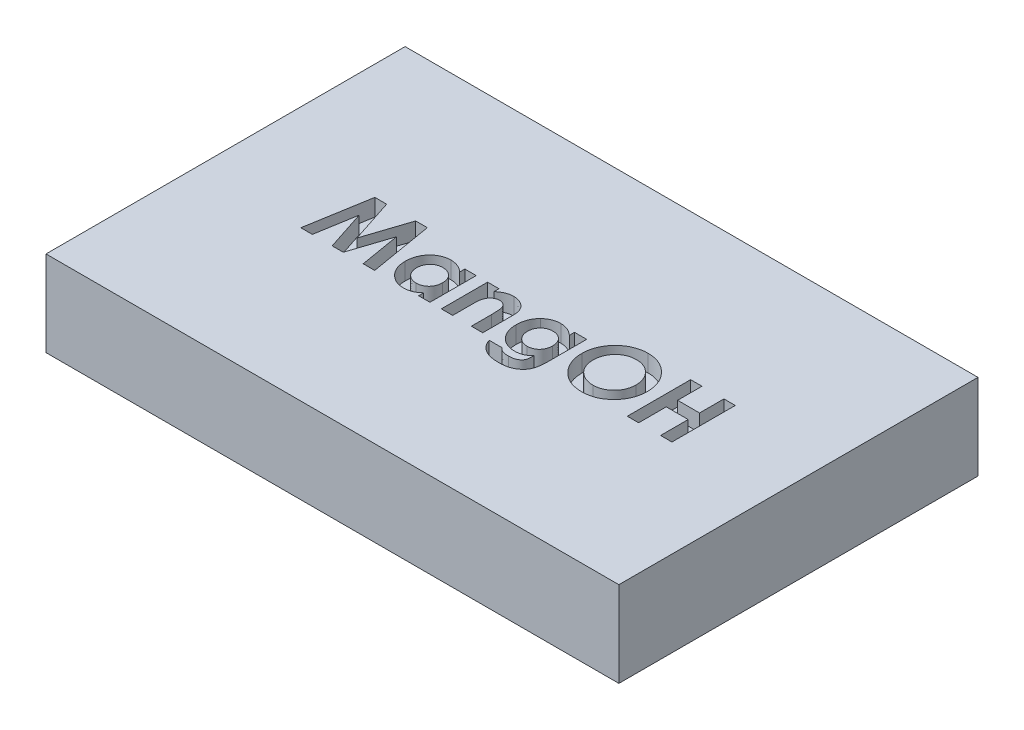
from build123d import *

# Parameters (mm, degrees)
SKETCH4_W           = 67
SKETCH4_H           = 42
BOSS_EXTRUDE1_DEPTH = 10
CUT_EXTRUDE1_DEPTH  = 2


with BuildPart() as part:
    # Sketch4 → Boss-Extrude1 (new body)
    with BuildSketch(Plane(origin=(0, 0, 0), x_dir=(1, 0, 0), z_dir=(0, 1, 0))):
        Rectangle(SKETCH4_W, SKETCH4_H)
    extrude(amount=BOSS_EXTRUDE1_DEPTH)

    # Sketch5 → Cut-Extrude1 (cut)
    with BuildSketch(Plane(origin=(0, 10, 0), x_dir=(1, 0, 0), z_dir=(0, 1, 0))):
        Polygon((-20.000405703, 3.960288306), (-18.62024745, 3.960288306), (-16.9299246, -1.207142917), (-15.227729421, 3.960288306), (-13.860927538, 3.960288306), (-12.608396822, -3.448045027), (-13.954422129, -3.448045027), (-14.745416053, 1.231136664), (-16.285850749, -3.448045027), (-17.582902698, -3.448045027), (-19.114433147, 1.231136664), (-19.90394303, -3.448045027), (-21.251452378, -3.448045027), align=None)
        with BuildLine():
            Line((-7.479550668, 1.965737024), (-6.149849814, 1.965737024))
            Line((-6.149849814, 1.965737024), (-6.149849814, -3.448045027))
            Line((-6.149849814, -3.448045027), (-7.479550668, -3.448045027))
            Line((-7.479550668, -3.448045027), (-7.479550668, -2.857396656))
            add(Edge.make_bspline(
                [(-7.479550668, -2.857396656), (-7.545436856, -2.914889738), (-7.673308935, -3.026472456), (-7.874793953, -3.17125387), (-8.076867735, -3.290679824), (-8.280501249, -3.385796084), (-8.488824257, -3.456029652), (-8.703336601, -3.506880396), (-8.927127489, -3.536868324), (-9.079257451, -3.540950509), (-9.156517148, -3.54302366)],
                knots=[0, 0, 0, 0, 0.000262222, 0.000508921, 0.00074308, 0.000965513, 0.001181863, 0.001401441, 0.001626017, 0.00185776, 0.00185776, 0.00185776, 0.00185776], degree=3))
            add(Edge.make_bspline(
                [(-9.156517148, -3.54302366), (-9.243244593, -3.541072563), (-9.41462294, -3.537217087), (-9.666101638, -3.496631973), (-9.908929322, -3.43450741), (-10.142908884, -3.346593389), (-10.367614619, -3.232674053), (-10.584766207, -3.095721717), (-10.790641008, -2.930928533), (-10.986952861, -2.745424685), (-11.166694815, -2.541369131), (-11.323826928, -2.321594136), (-11.456277622, -2.089216722), (-11.564787387, -1.845007328), (-11.650144331, -1.589145189), (-11.710991617, -1.320818789), (-11.746891587, -1.039932295), (-11.751334991, -0.848603415), (-11.75358913, -0.751542289)],
                knots=[0, 0, 0, 0, 0.000259978, 0.000513732, 0.000762095, 0.001010999, 0.001261872, 0.001516717, 0.001779777, 0.002051665, 0.002326132, 0.002594223, 0.00286076, 0.003127165, 0.003394663, 0.003668632, 0.003951368, 0.004242483, 0.004242483, 0.004242483, 0.004242483], degree=3))
            add(Edge.make_bspline(
                [(-11.75358913, -0.751542289), (-11.751223403, -0.651035366), (-11.746582766, -0.453879837), (-11.712636781, -0.164563472), (-11.652912355, 0.110416059), (-11.571473808, 0.371439643), (-11.466717259, 0.618552374), (-11.339130781, 0.852159102), (-11.186978681, 1.071649218), (-11.011650357, 1.273286843), (-10.822338831, 1.458097467), (-10.619808965, 1.61898977), (-10.407227883, 1.755675268), (-10.184369682, 1.867263678), (-9.951266186, 1.953493554), (-9.708837684, 2.016534634), (-9.456007965, 2.054361497), (-9.283778312, 2.058580013), (-9.196586259, 2.060715657)],
                knots=[0, 0, 0, 0, 0.000301494, 0.000591414, 0.000872306, 0.001144538, 0.001410529, 0.001676189, 0.001941716, 0.002210049, 0.002476623, 0.002734351, 0.002984644, 0.003233526, 0.003480519, 0.003728882, 0.003983883, 0.004245344, 0.004245344, 0.004245344, 0.004245344], degree=3))
            add(Edge.make_bspline(
                [(-9.196586259, 2.060715657), (-9.115818166, 2.059037683), (-8.956007223, 2.055717577), (-8.721108163, 2.019667582), (-8.493289954, 1.965144524), (-8.273795356, 1.887458982), (-8.060824001, 1.78936518), (-7.858039131, 1.666446334), (-7.661004644, 1.523868669), (-7.540782628, 1.412512493), (-7.479550668, 1.355796119)],
                knots=[0, 0, 0, 0, 0.000242122, 0.000479071, 0.000711233, 0.000944033, 0.001176417, 0.001413367, 0.00165439, 0.001904573, 0.001904573, 0.001904573, 0.001904573], degree=3))
            Line((-7.479550668, 1.355796119), (-7.479550668, 1.965737024))
        make_face()
        with BuildLine():
            add(Edge.make_bspline(
                [(-8.917586526, 0.825993434), (-8.970571185, 0.824367682), (-9.074417658, 0.821181314), (-9.227138108, 0.802015087), (-9.373093043, 0.76824334), (-9.511241526, 0.718352837), (-9.643642475, 0.657578935), (-9.768285362, 0.581460623), (-9.886198902, 0.491490396), (-9.996689633, 0.389846431), (-10.097418215, 0.27812113), (-10.184252131, 0.156204619), (-10.258046931, 0.027381857), (-10.320458153, -0.108734483), (-10.365130428, -0.253755078), (-10.400510851, -0.405792018), (-10.418871, -0.566087366), (-10.422199116, -0.675323685), (-10.423888275, -0.730765714)],
                knots=[0, 0, 0, 0, 0.000158966, 0.000311562, 0.00046095, 0.000607397, 0.000751472, 0.000897308, 0.001044528, 0.001195769, 0.001347112, 0.001494959, 0.001643874, 0.001791996, 0.00194312, 0.002098293, 0.002259727, 0.002426105, 0.002426105, 0.002426105, 0.002426105], degree=3))
            add(Edge.make_bspline(
                [(-10.423888275, -0.730765714), (-10.422224919, -0.786710633), (-10.418947294, -0.896949449), (-10.400213985, -1.058596946), (-10.366106696, -1.212854788), (-10.316345446, -1.358475906), (-10.255575418, -1.49742521), (-10.181604628, -1.629061436), (-10.090744467, -1.75105709), (-9.989927586, -1.866299001), (-9.877170155, -1.969205554), (-9.758589413, -2.060577126), (-9.63256564, -2.137027661), (-9.500466105, -2.198815467), (-9.362735462, -2.249167336), (-9.217646985, -2.28251464), (-9.066622, -2.303832941), (-8.963664279, -2.306801653), (-8.911650361, -2.308301437)],
                knots=[0, 0, 0, 0, 0.000167861, 0.000330768, 0.000487388, 0.000640849, 0.000791682, 0.000941885, 0.001092674, 0.001247221, 0.00140056, 0.001549859, 0.001695696, 0.001841744, 0.001986793, 0.002134736, 0.002287528, 0.002443529, 0.002443529, 0.002443529, 0.002443529], degree=3))
            add(Edge.make_bspline(
                [(-8.911650361, -2.308301437), (-8.857678801, -2.306666571), (-8.751865202, -2.303461344), (-8.596653196, -2.284470029), (-8.448737562, -2.250574455), (-8.308733709, -2.200398318), (-8.174503211, -2.140060652), (-8.047257379, -2.06542975), (-7.92837702, -1.97566598), (-7.817260062, -1.873103151), (-7.715442789, -1.760465545), (-7.627408029, -1.636950293), (-7.550726532, -1.506507752), (-7.490420063, -1.366053784), (-7.442528269, -1.218045677), (-7.408167011, -1.061564863), (-7.38947648, -0.896442636), (-7.38622752, -0.783740282), (-7.384572036, -0.72631359)],
                knots=[0, 0, 0, 0, 0.000161931, 0.000317472, 0.000468305, 0.000616151, 0.000762922, 0.000909271, 0.001057675, 0.001208916, 0.001362355, 0.001512272, 0.001663215, 0.001815407, 0.001969811, 0.00212933, 0.002295185, 0.002467493, 0.002467493, 0.002467493, 0.002467493], degree=3))
            add(Edge.make_bspline(
                [(-7.384572036, -0.72631359), (-7.386206949, -0.669874611), (-7.38940041, -0.559632889), (-7.408247619, -0.397958336), (-7.442852822, -0.24455009), (-7.489758923, -0.099126168), (-7.551138263, 0.037980921), (-7.62787778, 0.165250986), (-7.714946849, 0.287093458), (-7.817891386, 0.396688098), (-7.928406399, 0.498508293), (-8.049035086, 0.585557541), (-8.175976988, 0.660578999), (-8.310012038, 0.722174509), (-8.452381342, 0.767326354), (-8.600549754, 0.802285774), (-8.756829008, 0.821169811), (-8.863126227, 0.824359321), (-8.917586526, 0.825993434)],
                knots=[0, 0, 0, 0, 0.000169343, 0.000330777, 0.000487398, 0.000640391, 0.000788512, 0.000936894, 0.00108561, 0.001236851, 0.001387091, 0.001535807, 0.001682156, 0.001828926, 0.001977226, 0.002129505, 0.002285047, 0.00244846, 0.00244846, 0.00244846, 0.00244846], degree=3))
        make_face(mode=Mode.SUBTRACT)
        with BuildLine():
            Line((-4.820148959, 1.965737024), (-3.490448104, 1.965737024))
            Line((-3.490448104, 1.965737024), (-3.490448104, 1.392897147))
            add(Edge.make_bspline(
                [(-3.490448104, 1.392897147), (-3.41458933, 1.451901664), (-3.269608465, 1.564670767), (-3.049212518, 1.708451947), (-2.841186032, 1.82613107), (-2.640891873, 1.915643833), (-2.4445615, 1.980044417), (-2.249015204, 2.026312394), (-2.051340903, 2.055939052), (-1.91845579, 2.059124309), (-1.852066694, 2.060715657)],
                knots=[0, 0, 0, 0, 0.000288202, 0.00055081, 0.000788646, 0.001004573, 0.001207778, 0.001407557, 0.001606938, 0.001805999, 0.001805999, 0.001805999, 0.001805999], degree=3))
            add(Edge.make_bspline(
                [(-1.852066694, 2.060715657), (-1.784723891, 2.058897076), (-1.652524311, 2.05532705), (-1.457867716, 2.030357611), (-1.271892243, 1.984880352), (-1.092506752, 1.924498853), (-0.92153708, 1.844798736), (-0.756888744, 1.750167779), (-0.602098332, 1.634900871), (-0.506771544, 1.547119128), (-0.458552071, 1.502716191)],
                knots=[0, 0, 0, 0, 0.000202026, 0.000396594, 0.000587367, 0.000775559, 0.000963477, 0.001152341, 0.00134438, 0.001540952, 0.001540952, 0.001540952, 0.001540952], degree=3))
            add(Edge.make_bspline(
                [(-0.458552071, 1.502716191), (-0.419878278, 1.461567652), (-0.342247647, 1.378969416), (-0.244559252, 1.23762268), (-0.16073162, 1.083528866), (-0.092046524, 0.914910451), (-0.041291005, 0.730840988), (-0.002244092, 0.533543771), (0.019665812, 0.321914083), (0.022370693, 0.176526484), (0.023761297, 0.101781362)],
                knots=[0, 0, 0, 0, 0.000169213, 0.000339665, 0.000513653, 0.000694712, 0.000884495, 0.001085608, 0.001297515, 0.001521728, 0.001521728, 0.001521728, 0.001521728], degree=3))
            Line((0.023761297, 0.101781362), (0.023761297, -3.448045027))
            Line((0.023761297, -3.448045027), (-1.305939557, -3.448045027))
            Line((-1.305939557, -3.448045027), (-1.305939557, -1.097323873))
            add(Edge.make_bspline(
                [(-1.305939557, -1.097323873), (-1.30622076, -1.020647444), (-1.306759632, -0.8737113), (-1.310896978, -0.663423595), (-1.318975487, -0.473506489), (-1.326338837, -0.303614198), (-1.340796022, -0.154349953), (-1.353833744, -0.024768798), (-1.373838865, 0.083953698), (-1.399868773, 0.200901056), (-1.445323404, 0.326114587), (-1.515889502, 0.458047729), (-1.605412492, 0.570127875), (-1.710235899, 0.663140761), (-1.830243953, 0.736722486), (-1.963986532, 0.788491812), (-2.110746616, 0.820755727), (-2.213007317, 0.824203111), (-2.26611417, 0.825993434)],
                knots=[0, 0, 0, 0, 0.000230031, 0.000440812, 0.000630914, 0.000800329, 0.000950811, 0.001080773, 0.001190812, 0.001282246, 0.001439974, 0.001588734, 0.001729186, 0.001867958, 0.002007181, 0.002149107, 0.002296394, 0.002455526, 0.002455526, 0.002455526, 0.002455526], degree=3))
            add(Edge.make_bspline(
                [(-2.26611417, 0.825993434), (-2.335181866, 0.822490993), (-2.470291706, 0.815639537), (-2.665701061, 0.763973307), (-2.845181297, 0.676104258), (-3.007265914, 0.554511163), (-3.150411191, 0.404389421), (-3.268309439, 0.225352022), (-3.365010223, 0.021720024), (-3.406592997, -0.126964411), (-3.428118377, -0.203931112)],
                knots=[0, 0, 0, 0, 0.000207049, 0.000405028, 0.000601488, 0.000803023, 0.001009817, 0.001220556, 0.001443617, 0.001683003, 0.001683003, 0.001683003, 0.001683003], degree=3))
            add(Edge.make_bspline(
                [(-3.428118377, -0.203931112), (-3.433468289, -0.22810302), (-3.445399668, -0.282011234), (-3.455211719, -0.373083271), (-3.468860993, -0.481131424), (-3.47397504, -0.608111062), (-3.482867806, -0.753421243), (-3.486156776, -0.917254208), (-3.489451631, -1.09928871), (-3.490104942, -1.226432892), (-3.490448104, -1.293217303)],
                knots=[0, 0, 0, 0, 7.4217e-05, 0.000165519, 0.000274502, 0.000400864, 0.000546489, 0.000711278, 0.000892355, 0.001092706, 0.001092706, 0.001092706, 0.001092706], degree=3))
            Line((-3.490448104, -1.293217303), (-3.490448104, -3.448045027))
            Line((-3.490448104, -3.448045027), (-4.820148959, -3.448045027))
            Line((-4.820148959, -3.448045027), (-4.820148959, 1.965737024))
        make_face()
        with BuildLine():
            Line((5.342564716, 1.965737024), (6.767244203, 1.965737024))
            Line((6.767244203, 1.965737024), (6.767244203, -2.65259898))
            add(Edge.make_bspline(
                [(6.767244203, -2.65259898), (6.76553211, -2.762962502), (6.76222599, -2.976078797), (6.737005962, -3.284939355), (6.694948316, -3.571270082), (6.634428848, -3.835476487), (6.556265045, -4.076587487), (6.460667749, -4.295404658), (6.34958065, -4.493101455), (6.258242329, -4.608620439), (6.213696861, -4.664958756)],
                knots=[0, 0, 0, 0, 0.000331061, 0.000639292, 0.000928927, 0.001198557, 0.001451511, 0.001688084, 0.001914127, 0.002129313, 0.002129313, 0.002129313, 0.002129313], degree=3))
            add(Edge.make_bspline(
                [(6.213696861, -4.664958756), (6.149728953, -4.735124256), (6.022116992, -4.875100025), (5.797129952, -5.051744492), (5.550648362, -5.202719345), (5.280156835, -5.326450473), (4.985977556, -5.42069412), (4.668866244, -5.488566343), (4.328621859, -5.53084036), (4.093624166, -5.535288057), (3.972794751, -5.537574942)],
                knots=[0, 0, 0, 0, 0.000284429, 0.000567418, 0.000854518, 0.001150025, 0.001457422, 0.00177936, 0.002121736, 0.002484088, 0.002484088, 0.002484088, 0.002484088], degree=3))
            add(Edge.make_bspline(
                [(3.972794751, -5.537574942), (3.845071068, -5.535597625), (3.599425538, -5.531794736), (3.246437977, -5.494593765), (2.924900322, -5.433382133), (2.633302638, -5.347204831), (2.368928261, -5.236011188), (2.126791761, -5.102683594), (1.907358152, -4.943279482), (1.707310594, -4.764083131), (1.531288566, -4.561159296), (1.380983023, -4.336365886), (1.252930515, -4.091770551), (1.189703133, -3.916856908), (1.157568723, -3.827959557)],
                knots=[0, 0, 0, 0, 0.000383067, 0.000736736, 0.001063292, 0.001363788, 0.001647127, 0.001922151, 0.002191107, 0.002459045, 0.002726255, 0.00299462, 0.003268751, 0.003552063, 0.003552063, 0.003552063, 0.003552063], degree=3))
            Line((1.157568723, -3.827959557), (2.63567369, -3.827959557))
            add(Edge.make_bspline(
                [(2.63567369, -3.827959557), (2.669831116, -3.865563627), (2.738580043, -3.941249642), (2.860178157, -4.037290067), (2.994693234, -4.119495989), (3.143210534, -4.186809391), (3.306349309, -4.237995197), (3.482999048, -4.276882665), (3.673951003, -4.298797788), (3.805538158, -4.301473526), (3.873363995, -4.302852719)],
                knots=[0, 0, 0, 0, 0.000152192, 0.000306318, 0.000462848, 0.000624233, 0.000794128, 0.000974895, 0.001166152, 0.001369601, 0.001369601, 0.001369601, 0.001369601], degree=3))
            add(Edge.make_bspline(
                [(3.873363995, -4.302852719), (3.959078018, -4.301251202), (4.122784289, -4.298192443), (4.354392549, -4.264748245), (4.561223267, -4.214784568), (4.74029074, -4.139590453), (4.894780971, -4.049271976), (5.023663442, -3.94435532), (5.13008288, -3.828793245), (5.199692328, -3.720077567), (5.241056852, -3.62145482), (5.269223626, -3.536295497), (5.290613777, -3.438133922), (5.310084457, -3.328807322), (5.324639107, -3.206907208), (5.33428175, -3.072691825), (5.342643367, -2.926752498), (5.342591513, -2.82525618), (5.342564716, -2.772806312)],
                knots=[0, 0, 0, 0, 0.000256949, 0.00049075, 0.000700594, 0.000893519, 0.001071171, 0.001235732, 0.001390165, 0.001540867, 0.001619982, 0.001710557, 0.001809555, 0.001921055, 0.002043648, 0.002177615, 0.002324723, 0.002482038, 0.002482038, 0.002482038, 0.002482038], degree=3))
            add(Edge.make_bspline(
                [(5.342564716, -2.772806312), (5.284310926, -2.829940799), (5.17063487, -2.941432656), (4.986099553, -3.083672262), (4.797194979, -3.201158675), (4.602835542, -3.294555229), (4.399155875, -3.362966557), (4.184959694, -3.412099955), (3.957807572, -3.442037717), (3.801726882, -3.446013809), (3.721991799, -3.448045027)],
                knots=[0, 0, 0, 0, 0.000244615, 0.00047734, 0.000697258, 0.000911002, 0.001122658, 0.001340454, 0.001569444, 0.0018086, 0.0018086, 0.0018086, 0.0018086], degree=3))
            add(Edge.make_bspline(
                [(3.721991799, -3.448045027), (3.633795518, -3.446007526), (3.460546745, -3.442005151), (3.206079951, -3.40310989), (2.961941691, -3.342592659), (2.727474573, -3.258347014), (2.505071076, -3.146498596), (2.291566316, -3.013430177), (2.09091716, -2.852154441), (1.900355413, -2.671674325), (1.728121323, -2.471062779), (1.576565975, -2.255606249), (1.448801016, -2.02679095), (1.34489877, -1.784829591), (1.262115241, -1.530737915), (1.20514255, -1.263140332), (1.170327808, -0.982488666), (1.165809431, -0.791219323), (1.163504887, -0.693664685)],
                knots=[0, 0, 0, 0, 0.000264426, 0.000519426, 0.0007703, 0.001018174, 0.001265066, 0.001515816, 0.001771459, 0.002035976, 0.002302216, 0.002563243, 0.002825007, 0.003086905, 0.003352067, 0.003625393, 0.003906473, 0.00419907, 0.00419907, 0.00419907, 0.00419907], degree=3))
            add(Edge.make_bspline(
                [(1.163504887, -0.693664685), (1.165517678, -0.589658227), (1.169451427, -0.386390565), (1.208013391, -0.089492188), (1.268017673, 0.192479286), (1.353675362, 0.458934032), (1.466210343, 0.708732971), (1.602204366, 0.942668737), (1.760374563, 1.163416476), (1.885579486, 1.294372197), (1.948562646, 1.360248242)],
                knots=[0, 0, 0, 0, 0.000311875, 0.00060952, 0.000896528, 0.001175768, 0.001447449, 0.001716752, 0.001986579, 0.002259707, 0.002259707, 0.002259707, 0.002259707], degree=3))
            add(Edge.make_bspline(
                [(1.948562646, 1.360248242), (2.008332757, 1.416419205), (2.126112745, 1.527106892), (2.318918219, 1.669137566), (2.518601333, 1.790957452), (2.727900961, 1.888947816), (2.945336098, 1.966981977), (3.172193981, 2.021573066), (3.407346612, 2.055232673), (3.567043851, 2.058874355), (3.647789743, 2.060715657)],
                knots=[0, 0, 0, 0, 0.000245877, 0.000484512, 0.000716882, 0.000946578, 0.00117658, 0.001408741, 0.001645482, 0.001887603, 0.001887603, 0.001887603, 0.001887603], degree=3))
            add(Edge.make_bspline(
                [(3.647789743, 2.060715657), (3.723560623, 2.058588037), (3.873705423, 2.054372023), (4.096154782, 2.024626264), (4.311558233, 1.972076063), (4.522274293, 1.899830586), (4.730536379, 1.806244796), (4.936164522, 1.683582592), (5.143327768, 1.536913261), (5.274780086, 1.422311702), (5.342564716, 1.363216324)],
                knots=[0, 0, 0, 0, 0.000227296, 0.000450401, 0.000671767, 0.000891405, 0.001117886, 0.001355355, 0.001608609, 0.00187824, 0.00187824, 0.00187824, 0.00187824], degree=3))
            Line((5.342564716, 1.363216324), (5.342564716, 1.965737024))
        make_face()
        with BuildLine():
            add(Edge.make_bspline(
                [(3.965374545, 0.825993434), (3.913389493, 0.8243183), (3.811044326, 0.821020391), (3.660629237, 0.802439651), (3.517884624, 0.767366719), (3.381070763, 0.721825745), (3.251851075, 0.660564113), (3.129975758, 0.585820017), (3.014000202, 0.499062746), (2.907614812, 0.398655163), (2.809002851, 0.290162475), (2.726204808, 0.170760084), (2.652416992, 0.04724696), (2.595036017, -0.085347005), (2.547586985, -0.223423493), (2.518588096, -0.369792288), (2.495417087, -0.52177805), (2.49395243, -0.625795649), (2.493205742, -0.678824274)],
                knots=[0, 0, 0, 0, 0.000156001, 0.000307126, 0.000453625, 0.000596294, 0.000739025, 0.000881554, 0.001024616, 0.001172671, 0.001319823, 0.00146353, 0.001607849, 0.001750695, 0.001896177, 0.002044914, 0.002197706, 0.002356609, 0.002356609, 0.002356609, 0.002356609], degree=3))
            add(Edge.make_bspline(
                [(2.493205742, -0.678824274), (2.494014002, -0.733815698), (2.495600312, -0.841743144), (2.517810107, -0.998973273), (2.549536473, -1.149451968), (2.597461761, -1.291342363), (2.657459796, -1.426508822), (2.729531364, -1.554884922), (2.818499686, -1.673401251), (2.917295972, -1.784666005), (3.026591359, -1.885262073), (3.144238174, -1.972759035), (3.267814285, -2.048321668), (3.399991004, -2.107236527), (3.537908437, -2.154977994), (3.682949867, -2.18964784), (3.834781985, -2.208379761), (3.938119985, -2.211657904), (3.990603244, -2.213322805)],
                knots=[0, 0, 0, 0, 0.000164835, 0.00032351, 0.000475463, 0.000625637, 0.000771799, 0.000918689, 0.001066207, 0.001215455, 0.001364599, 0.001510926, 0.001654725, 0.001798179, 0.001944136, 0.002092079, 0.002244676, 0.002402159, 0.002402159, 0.002402159, 0.002402159], degree=3))
            add(Edge.make_bspline(
                [(3.990603244, -2.213322805), (4.042135498, -2.21251482), (4.143173958, -2.210930618), (4.290560502, -2.188707356), (4.431376216, -2.1565744), (4.565367496, -2.110624195), (4.691790719, -2.050649204), (4.812342339, -1.979078148), (4.92446522, -1.892469025), (5.03028579, -1.794551453), (5.125782101, -1.685669706), (5.210073376, -1.567697761), (5.279315604, -1.440614315), (5.338295818, -1.306431372), (5.381964891, -1.163256123), (5.415121946, -1.012510322), (5.434571682, -0.85346369), (5.436540007, -0.744669661), (5.437543349, -0.689212562)],
                knots=[0, 0, 0, 0, 0.000154454, 0.000302836, 0.000446106, 0.000587371, 0.000726784, 0.000865238, 0.001007117, 0.001150977, 0.001297146, 0.001440853, 0.001584996, 0.00173056, 0.001879823, 0.002033226, 0.002193186, 0.002359504, 0.002359504, 0.002359504, 0.002359504], degree=3))
            add(Edge.make_bspline(
                [(5.437543349, -0.689212562), (5.436569923, -0.634245317), (5.434669261, -0.526919012), (5.414944867, -0.36989323), (5.382075967, -0.221038318), (5.337802007, -0.079125766), (5.280103126, 0.054996954), (5.207748985, 0.180081527), (5.125008949, 0.298437693), (5.027585429, 0.406033929), (4.922577312, 0.505550368), (4.806808481, 0.58973915), (4.686068589, 0.66412532), (4.556280996, 0.723096044), (4.419057799, 0.769542903), (4.274178604, 0.801315198), (4.122382292, 0.82361028), (4.018390178, 0.825188732), (3.965374545, 0.825993434)],
                knots=[0, 0, 0, 0, 0.000164835, 0.00032185, 0.000473803, 0.000621649, 0.000767214, 0.000910791, 0.001054498, 0.001199554, 0.001345512, 0.001487686, 0.001628177, 0.001770281, 0.001914355, 0.002061963, 0.002214755, 0.002373658, 0.002373658, 0.002373658, 0.002373658], degree=3))
        make_face(mode=Mode.SUBTRACT)
        with BuildLine():
            add(Edge.make_bspline(
                [(11.76846282, 4.150245571), (11.897265774, 4.146910632), (12.151551979, 4.140326707), (12.525515225, 4.085444551), (12.885897958, 3.996021948), (13.232537213, 3.87171806), (13.564565047, 3.709166109), (13.883152633, 3.512974547), (14.187158804, 3.279440377), (14.47346835, 3.014011567), (14.738070007, 2.725369325), (14.967347498, 2.414594635), (15.16286693, 2.089739981), (15.324913959, 1.749934906), (15.448342934, 1.392826098), (15.534958151, 1.02023434), (15.590604136, 0.63226563), (15.597004281, 0.368111819), (15.600257024, 0.233861022)],
                knots=[0, 0, 0, 0, 0.000386261, 0.000762568, 0.001131139, 0.001498705, 0.00186508, 0.002238221, 0.00261934, 0.00301317, 0.003408187, 0.003792264, 0.004169704, 0.004544106, 0.004919572, 0.005300774, 0.005690306, 0.006092875, 0.006092875, 0.006092875, 0.006092875], degree=3))
            add(Edge.make_bspline(
                [(15.600257024, 0.233861022), (15.596792993, 0.101122922), (15.589967009, -0.160441763), (15.537229863, -0.544835188), (15.449156036, -0.913435713), (15.327820513, -1.267077672), (15.168712405, -1.604048145), (14.977005814, -1.926498642), (14.747641968, -2.231436745), (14.488986668, -2.518698813), (14.204229629, -2.779450779), (13.90262672, -3.009237999), (13.585570558, -3.203951018), (13.25352521, -3.363500647), (12.905778622, -3.487321238), (12.543189771, -3.574685663), (12.165781092, -3.627778788), (11.909124889, -3.634560185), (11.778851108, -3.638002292)],
                knots=[0, 0, 0, 0, 0.000398122, 0.000784511, 0.001161382, 0.001533557, 0.001904008, 0.002277377, 0.002656996, 0.003046824, 0.003435456, 0.003813595, 0.004182653, 0.004549719, 0.004916784, 0.005287884, 0.005666922, 0.006057631, 0.006057631, 0.006057631, 0.006057631], degree=3))
            add(Edge.make_bspline(
                [(11.778851108, -3.638002292), (11.642600353, -3.634914552), (11.374886244, -3.628847565), (10.983085447, -3.571153287), (10.607706429, -3.48424555), (10.25190259, -3.354540414), (9.912050372, -3.192398088), (9.590646768, -2.992710093), (9.287799793, -2.755806428), (9.005246625, -2.487754284), (8.749252771, -2.194446446), (8.523287981, -1.884592726), (8.332681668, -1.560560133), (8.177426858, -1.222197013), (8.055030203, -0.87160621), (7.968693269, -0.506652527), (7.917691982, -0.128211253), (7.910587799, 0.128833626), (7.906987793, 0.259089722)],
                knots=[0, 0, 0, 0, 0.0004085, 0.000802646, 0.001185635, 0.001562584, 0.001936286, 0.002313513, 0.002695269, 0.003087876, 0.003480171, 0.003861616, 0.004236782, 0.004605983, 0.004976756, 0.005348952, 0.00572926, 0.006119969, 0.006119969, 0.006119969, 0.006119969], degree=3))
            add(Edge.make_bspline(
                [(7.906987793, 0.259089722), (7.908117682, 0.346719204), (7.910363154, 0.520868579), (7.937412226, 0.778949063), (7.976355113, 1.031992162), (8.033949794, 1.27898899), (8.103912612, 1.521681995), (8.194559325, 1.757812131), (8.297739815, 1.989901915), (8.418296504, 2.215210078), (8.552343884, 2.431663595), (8.698601511, 2.638241419), (8.857437147, 2.832445721), (9.02833913, 3.015552732), (9.211896411, 3.186358875), (9.405694484, 3.347282151), (9.613491903, 3.494047864), (9.830740635, 3.630240325), (10.05621588, 3.753396807), (10.288999751, 3.85822392), (10.52429644, 3.949767653), (10.765249192, 4.022018015), (11.009275772, 4.080865179), (11.258983107, 4.119781818), (11.512115236, 4.146830141), (11.682810837, 4.149104392), (11.76846282, 4.150245571)],
                knots=[0, 0, 0, 0, 0.00026278, 0.000522233, 0.000777682, 0.001030405, 0.001282574, 0.001534778, 0.001788527, 0.002044132, 0.002300704, 0.002551888, 0.002802906, 0.003052799, 0.003302691, 0.00355465, 0.003807905, 0.004065261, 0.004323578, 0.004577938, 0.00483067, 0.005080421, 0.005332035, 0.005583088, 0.00583811, 0.006094957, 0.006094957, 0.006094957, 0.006094957], degree=3))
        make_face()
        with BuildLine():
            add(Edge.make_bspline(
                [(11.747686244, 2.820544716), (11.661001873, 2.81821878), (11.489921612, 2.813628313), (11.238978025, 2.778655159), (10.99806332, 2.722799057), (10.768512982, 2.641892176), (10.54933212, 2.538918251), (10.340132193, 2.414237085), (10.143810189, 2.263562903), (9.957748344, 2.094984729), (9.789672083, 1.907149901), (9.641171404, 1.705852939), (9.516900255, 1.491430005), (9.412822389, 1.265873037), (9.334474822, 1.026645706), (9.2786702, 0.775621907), (9.243403762, 0.512369112), (9.238958383, 0.332910025), (9.236688648, 0.241281228)],
                knots=[0, 0, 0, 0, 0.000259978, 0.000513093, 0.000758589, 0.001000774, 0.001241765, 0.00148406, 0.00172982, 0.001982983, 0.00223625, 0.002484693, 0.002732096, 0.002978474, 0.003228609, 0.003485673, 0.003749085, 0.00402389, 0.00402389, 0.00402389, 0.00402389], degree=3))
            add(Edge.make_bspline(
                [(9.236688648, 0.241281228), (9.239697971, 0.139735909), (9.245595745, -0.05927609), (9.287093201, -0.349589433), (9.358091217, -0.623761573), (9.460610973, -0.880451572), (9.587762366, -1.122509784), (9.745664216, -1.346969438), (9.931759261, -1.555174496), (10.075125376, -1.676733282), (10.147889903, -1.738429643)],
                knots=[0, 0, 0, 0, 0.00030459, 0.000596946, 0.000877713, 0.001152192, 0.001424383, 0.001696109, 0.001973533, 0.002259457, 0.002259457, 0.002259457, 0.002259457], degree=3))
            add(Edge.make_bspline(
                [(10.147889903, -1.738429643), (10.207497943, -1.784008544), (10.325371042, -1.874139448), (10.513522173, -1.98966069), (10.707280788, -2.088673919), (10.908109041, -2.168675436), (11.115582791, -2.231603285), (11.329673589, -2.275670623), (11.550078084, -2.303326689), (11.699125934, -2.306632112), (11.774398984, -2.308301437)],
                knots=[0, 0, 0, 0, 0.000224988, 0.000444906, 0.000661271, 0.00087705, 0.001092543, 0.001310833, 0.00153209, 0.00175784, 0.00175784, 0.00175784, 0.00175784], degree=3))
            add(Edge.make_bspline(
                [(11.774398984, -2.308301437), (11.859592816, -2.30595578), (12.027214358, -2.301340625), (12.273486494, -2.266798009), (12.50942268, -2.208339433), (12.736487628, -2.128142296), (12.954026585, -2.023875444), (13.160976377, -1.89532706), (13.357699844, -1.744075551), (13.54352465, -1.573283576), (13.713377306, -1.38470881), (13.861568095, -1.18233815), (13.989790446, -0.97063043), (14.091704011, -0.746589246), (14.173146912, -0.512329443), (14.228279897, -0.266813534), (14.263844257, -0.01105363), (14.268290888, 0.163000023), (14.270556169, 0.251669516)],
                knots=[0, 0, 0, 0, 0.000255531, 0.000502765, 0.000744281, 0.000983668, 0.001223954, 0.001466526, 0.001713185, 0.00196735, 0.002222713, 0.002473231, 0.002718834, 0.002963862, 0.003210254, 0.00346153, 0.003717586, 0.003983495, 0.003983495, 0.003983495, 0.003983495], degree=3))
            add(Edge.make_bspline(
                [(14.270556169, 0.251669516), (14.268212509, 0.339829136), (14.26359937, 0.513357901), (14.228995958, 0.768460248), (14.170908111, 1.012892276), (14.090470151, 1.247053167), (13.987755134, 1.471172487), (13.860737596, 1.6844621), (13.709863226, 1.886715806), (13.538604387, 2.076555324), (13.352199667, 2.251005681), (13.152075574, 2.402396879), (12.943831806, 2.533951016), (12.722690234, 2.637005215), (12.49317523, 2.719108277), (12.253886281, 2.77957015), (12.003917065, 2.813382624), (11.833857839, 2.818136072), (11.747686244, 2.820544716)],
                knots=[0, 0, 0, 0, 0.000264426, 0.000520482, 0.000770652, 0.001017043, 0.001262072, 0.00150895, 0.001760349, 0.002017808, 0.002275078, 0.002524997, 0.002769612, 0.003012578, 0.003255258, 0.003500013, 0.003751657, 0.004010153, 0.004010153, 0.004010153, 0.004010153], degree=3))
        make_face(mode=Mode.SUBTRACT)
        Polygon((16.929957879, 3.960288306), (18.259658733, 3.960288306), (18.259658733, 1.110929332), (20.82408181, 1.110929332), (20.82408181, 3.960288306), (22.153782665, 3.960288306), (22.153782665, -3.448045027), (20.82408181, -3.448045027), (20.82408181, -0.218771523), (18.259658733, -0.218771523), (18.259658733, -3.448045027), (16.929957879, -3.448045027), align=None)
    extrude(amount=-CUT_EXTRUDE1_DEPTH, mode=Mode.SUBTRACT)


solid = part.part
